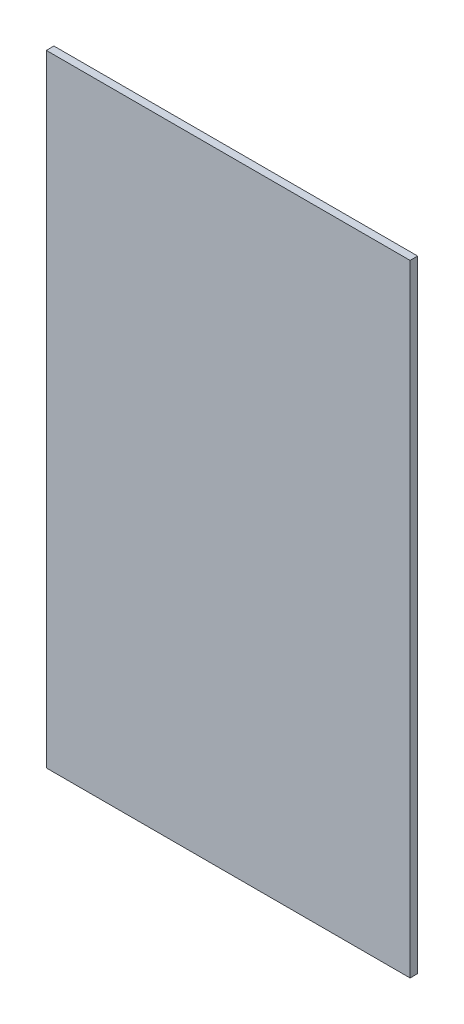
from build123d import *

# Parameters (mm, degrees)
SKETCH1_W           = 240
SKETCH1_H           = 410
BOSS_EXTRUDE1_DEPTH = 5


with BuildPart() as part:
    # Sketch1 → Boss-Extrude1 (new body)
    with BuildSketch(Plane.XY):
        with Locations((120, -205)):
            Rectangle(SKETCH1_W, SKETCH1_H)
    extrude(amount=BOSS_EXTRUDE1_DEPTH)


solid = part.part
